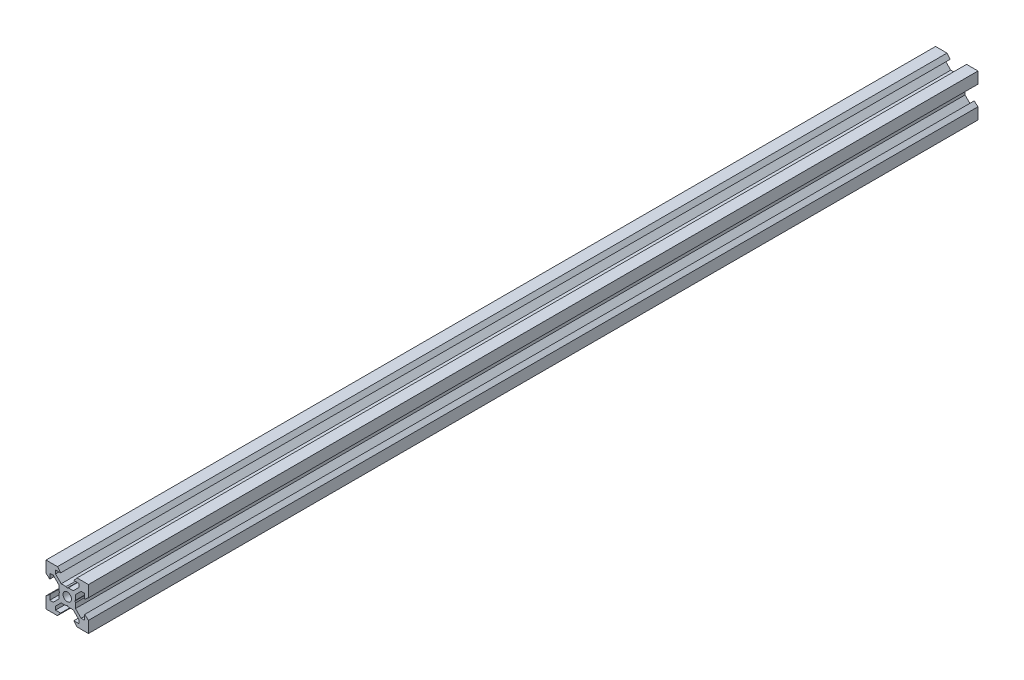
from build123d import *

# Parameters (mm, degrees)
SKETCH1_R           = 2
BOSS_EXTRUDE1_DEPTH = 209.55


with BuildPart() as part:
    # Sketch1 → Boss-Extrude1 (new body, symmetric)
    with BuildSketch(Plane.XY):
        Polygon((10, 10), (10, 4.610379336), (8.2, 3.1), (8.2, 5.5), (6.560660172, 5.5), (3.9, 2.839339828), (3.9, 0.519615242), (3.6, 0), (3.9, -0.519615242), (3.9, -2.839339828), (6.560660172, -5.5), (8.2, -5.5), (8.2, -3.1), (10, -4.610379336), (10, -10), (4.610379336, -10), (3.1, -8.2), (5.5, -8.2), (5.5, -6.560660172), (2.839339828, -3.9), (0.519615242, -3.9), (0, -3.6), (-0.519615242, -3.9), (-2.839339828, -3.9), (-5.5, -6.560660172), (-5.5, -8.2), (-3.1, -8.2), (-4.610379336, -10), (-10, -10), (-10, -4.610379336), (-8.2, -3.1), (-8.2, -5.5), (-6.560660172, -5.5), (-3.9, -2.839339828), (-3.9, -0.519615242), (-3.6, 0), (-3.9, 0.519615242), (-3.9, 2.839339828), (-6.560660172, 5.5), (-8.2, 5.5), (-8.2, 3.1), (-10, 4.610379336), (-10, 10), (-4.610379336, 10), (-3.1, 8.2), (-5.5, 8.2), (-5.5, 6.560660172), (-2.839339828, 3.9), (-0.519615242, 3.9), (0, 3.6), (0.519615242, 3.9), (2.839339828, 3.9), (5.5, 6.560660172), (5.5, 8.2), (3.1, 8.2), (4.610379336, 10), align=None)
        Circle(SKETCH1_R, mode=Mode.SUBTRACT)
    extrude(amount=BOSS_EXTRUDE1_DEPTH, both=True)


solid = part.part
